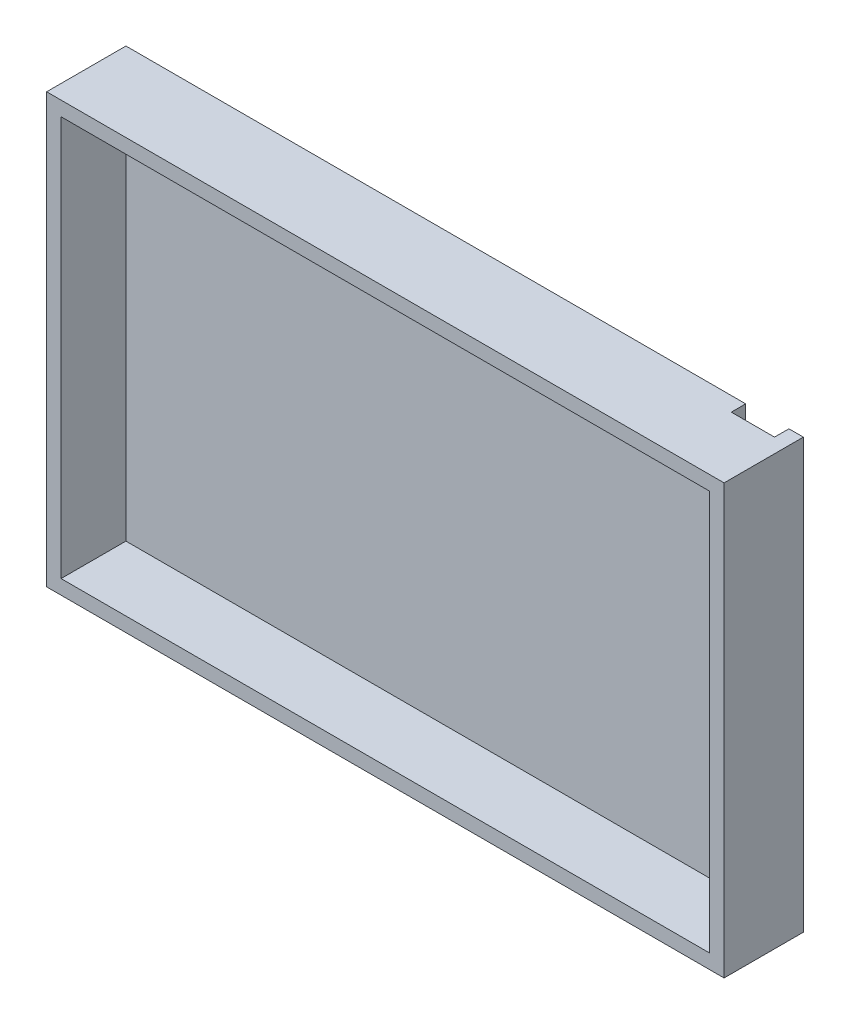
from build123d import *

# Parameters (mm, degrees)
SKETCH2_W           = 94
SKETCH2_H           = 59.5
BOSS_EXTRUDE1_DEPTH = 11
SKETCH3_W           = 90
SKETCH3_H           = 55.5
CUT_EXTRUDE1_DEPTH  = 9
SKETCH5_W           = 6
SKETCH5_H           = 59.5
CUT_EXTRUDE2_DEPTH  = 2


with BuildPart() as part:
    # Sketch2 → Boss-Extrude1 (new body)
    with BuildSketch(Plane.XY):
        Rectangle(SKETCH2_W, SKETCH2_H)
    extrude(amount=BOSS_EXTRUDE1_DEPTH)

    # Sketch3 → Cut-Extrude1 (cut)
    with BuildSketch(Plane.XY.offset(11)):
        Rectangle(SKETCH3_W, SKETCH3_H)
    extrude(amount=-CUT_EXTRUDE1_DEPTH, mode=Mode.SUBTRACT)

    # Sketch5 → Cut-Extrude2 (cut)
    with BuildSketch(Plane(origin=(0, 0, 0), x_dir=(-1, 0, 0), z_dir=(0, 0, -1))):
        with Locations((-42, 0)):
            Rectangle(SKETCH5_W, SKETCH5_H)
    extrude(amount=-CUT_EXTRUDE2_DEPTH, mode=Mode.SUBTRACT)


solid = part.part
